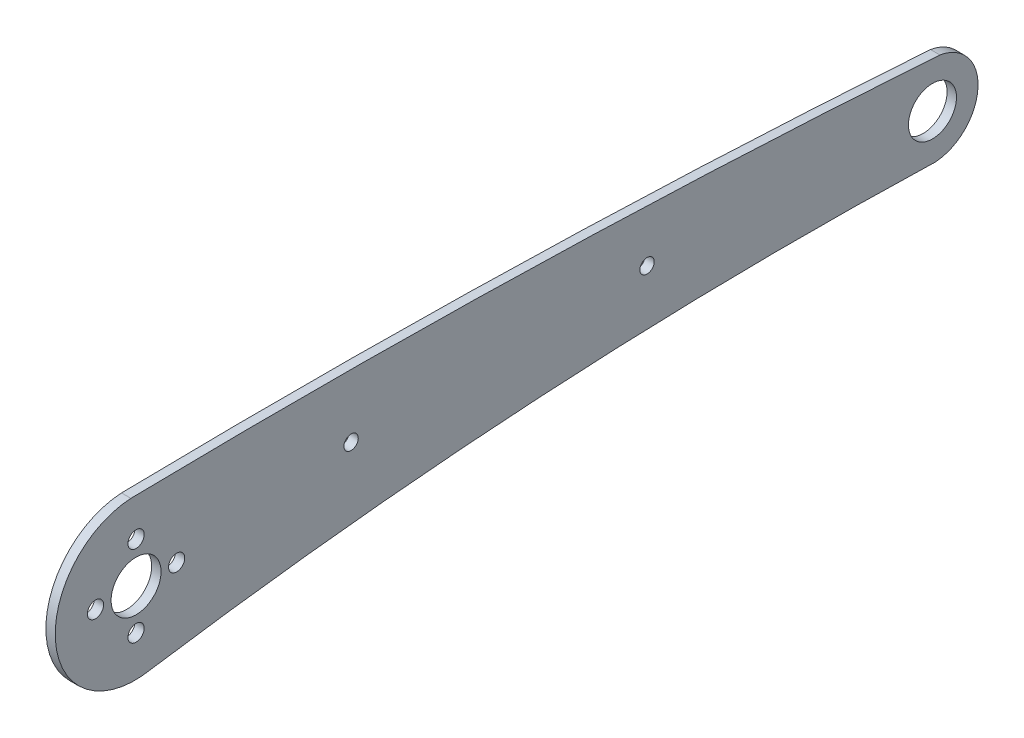
from build123d import *

# Parameters (mm, degrees)
SKETCH_1_R      = 1.3
SKETCH_1_R_2    = 3.85
SKETCH_1_R_3    = 4
SKETCH_1_R_4    = 1.149031008
EXTRUDE_1_DEPTH = 1.5


with BuildPart() as part:
    # 草圖1 → 填料-伸長1 (new body)
    with BuildSketch(Plane(origin=(0, 0, 0), x_dir=(0, 0, -1), z_dir=(1, 0, 0))):
        with BuildLine():
            ThreePointArc((66.587683924, -5.116627236), (3.80507147, -6.050846657), (-58.633451622, -12.681082444))
            ThreePointArc((-58.633451622, -12.681082444), (-73.821962275, -1.715080477), (-61.804017134, 12.655481431))
            ThreePointArc((-61.804017134, 12.655481431), (3.033906142, 12.458288366), (67.798504291, 9.369274541))
            ThreePointArc((67.798504291, 9.369274541), (73.912446594, 1.807845069), (67.095645487, -5.12661445))
            ThreePointArc((67.095645487, -5.12661445), (66.8414518, -5.132449469), (66.587683924, -5.116627236))
        make_face()
        with Locations((-67.469663313, 0.079585479)):
            Circle(SKETCH_1_R, mode=Mode.SUBTRACT)
        with Locations((-54.469663313, 0.079585479)):
            Circle(SKETCH_1_R, mode=Mode.SUBTRACT)
        with Locations((-60.969663313, 6.579585479)):
            Circle(SKETCH_1_R, mode=Mode.SUBTRACT)
        with Locations((-60.969663313, -6.420414521)):
            Circle(SKETCH_1_R, mode=Mode.SUBTRACT)
        with Locations((66.61714054, 2.16157088)):
            Circle(SKETCH_1_R_2, mode=Mode.SUBTRACT)
        with Locations((-60.969663313, 0.079585479)):
            Circle(SKETCH_1_R_3, mode=Mode.SUBTRACT)
        with Locations((20.89210292, 3.571177524)):
            Circle(SKETCH_1_R_4, mode=Mode.SUBTRACT)
        with Locations((-26.521912025, 2.797466734)):
            Circle(SKETCH_1_R_4, mode=Mode.SUBTRACT)
    extrude(amount=EXTRUDE_1_DEPTH)


solid = part.part
